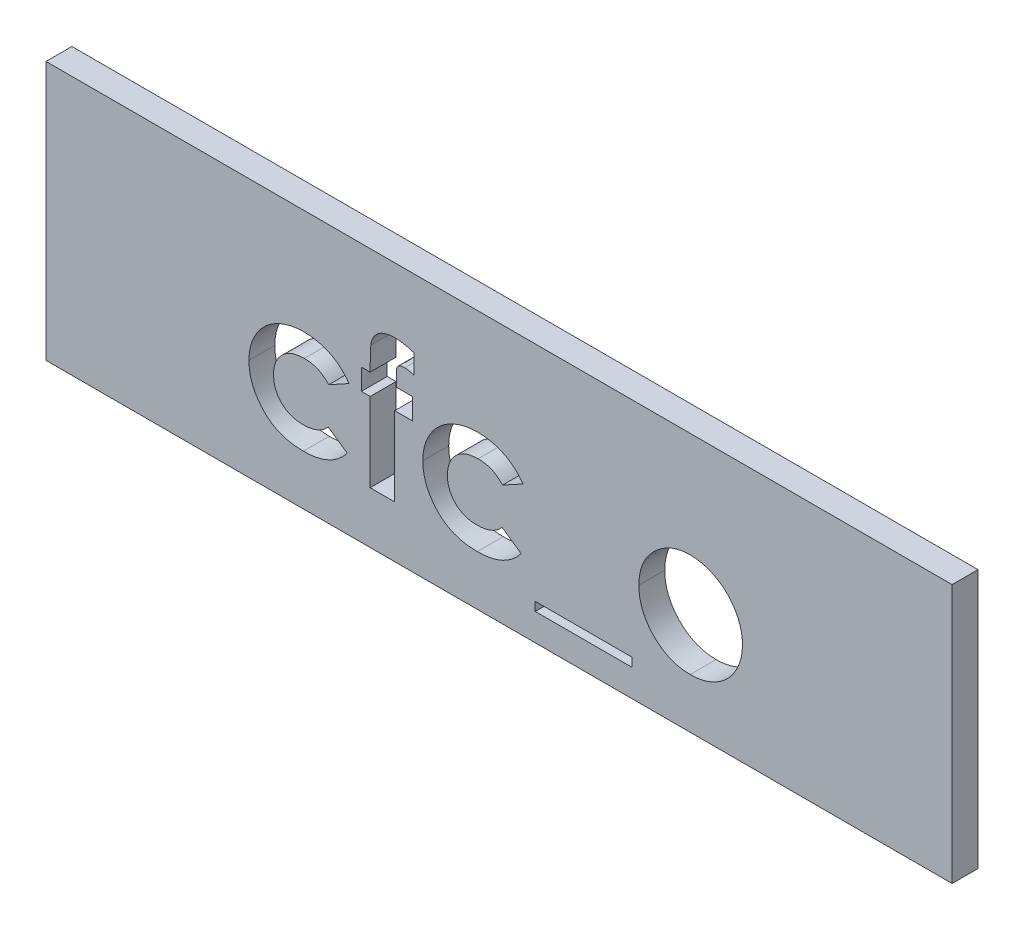
from build123d import *

# Parameters (mm, degrees)
ESQUISSE1_W             = 35
ESQUISSE1_H             = 10
BOSS_EXTRU_1_DEPTH      = 1
ESQUISSE2_R             = 1
BOSS_EXTRU_2_DEPTH      = 3
CHANFREIN1_SIZE         = 0.5
ESQUISSE3_W             = 3.731303419
ESQUISSE3_H             = 0.339209402
ENL_V_MAT_EXTRU_2_DEPTH = 1


with BuildPart() as part:
    # Esquisse1 → Boss.-Extru.1 (new body)
    with BuildSketch(Plane.XY):
        with Locations((17.5, -5)):
            Rectangle(ESQUISSE1_W, ESQUISSE1_H)
    extrude(amount=BOSS_EXTRU_1_DEPTH)

    # Esquisse2 → Boss.-Extru.2 (add)
    with BuildSketch(Plane(origin=(0, 0, 0), x_dir=(-1, 0, 0), z_dir=(0, 0, -1))):
        with Locations(Location((-30, -5, 0), (0, 0, 180))):  # turned: the seam where the file's is
            Circle(ESQUISSE2_R)
        with Locations(Location((-5, -5, 0), (0, 0, 180))):  # turned: the seam where the file's is
            Circle(ESQUISSE2_R)
    extrude(amount=BOSS_EXTRU_2_DEPTH)

    # Chanfrein1
    chanfrein1_edges = [part.edges().sort_by_distance(p)[0] for p in [
        (29, -5, -3),
        (4, -5, -3),
    ]]
    chamfer(chanfrein1_edges, length=CHANFREIN1_SIZE)

    # Esquisse3 → Enlèv. mat.-Extru.2 (cut)
    with BuildSketch(Plane.XY.offset(1)):
        with BuildLine():
            Line((11.706196581, -4.921674679), (10.919654781, -5.354166667))
            add(Edge.make_bspline(
                [(10.919654781, -5.354166667), (10.883602572, -5.318063555), (10.814301161, -5.248664299), (10.70317078, -5.16081585), (10.594026153, -5.088079778), (10.482367698, -5.034404293), (10.367197322, -4.993981508), (10.244360969, -4.96720861), (10.112424923, -4.949579608), (10.02116461, -4.947953728), (9.974108574, -4.947115385)],
                knots=[0, 0, 0, 0, 1.150764855, 2.212059359, 3.192108068, 4.105322427, 5.000809612, 5.941206042, 6.938435785, 8, 8, 8, 8], degree=3))
            add(Edge.make_bspline(
                [(9.974108574, -4.947115385), (9.930954941, -4.948157704), (9.846506901, -4.950197436), (9.723114912, -4.965432834), (9.605843472, -4.989361835), (9.494903088, -5.024370047), (9.390491357, -5.0706178), (9.291744837, -5.12534506), (9.199623087, -5.190689399), (9.115428271, -5.265721963), (9.039427651, -5.348331153), (8.971631221, -5.436437405), (8.916089934, -5.531347754), (8.868071046, -5.630831462), (8.832766975, -5.736757056), (8.806937657, -5.848163371), (8.792215187, -5.965055344), (8.790082161, -6.044912531), (8.788995726, -6.085586939)],
                knots=[0, 0, 0, 0, 1.121765476, 2.195200973, 3.227634963, 4.230038321, 5.213228299, 6.192116585, 7.160777141, 8.14345191, 9.118668839, 10.075979138, 11.027630062, 11.972829041, 12.943187208, 13.923755399, 14.94248691, 16, 16, 16, 16], degree=3))
            add(Edge.make_bspline(
                [(8.788995726, -6.085586939), (8.790143638, -6.125199879), (8.792385016, -6.202546952), (8.806155286, -6.316188233), (8.830060994, -6.424369883), (8.865904474, -6.526519978), (8.908866891, -6.623580196), (8.962819823, -6.714778598), (9.026265498, -6.800513425), (9.099537933, -6.880039516), (9.180705196, -6.951563477), (9.26820987, -7.01472654), (9.361790878, -7.068277132), (9.462538343, -7.110302311), (9.568809681, -7.144544041), (9.681314575, -7.168925493), (9.799933301, -7.182458885), (9.880792683, -7.184733534), (9.922167134, -7.185897436)],
                knots=[0, 0, 0, 0, 1.070556293, 2.090336998, 3.088792742, 4.058148387, 5.011235098, 5.952916408, 6.915475435, 7.888633318, 8.869583867, 9.83422472, 10.800707077, 11.776204622, 12.778807041, 13.814557445, 14.881744048, 16, 16, 16, 16], degree=3))
            add(Edge.make_bspline(
                [(9.922167134, -7.185897436), (9.973109, -7.184731737), (10.072540119, -7.182456462), (10.21708411, -7.163158313), (10.353098027, -7.131245961), (10.480596296, -7.08707673), (10.599400542, -7.029324638), (10.709205509, -6.958784767), (10.811139986, -6.875977477), (10.870582557, -6.811419049), (10.900574252, -6.778846154)],
                knots=[0, 0, 0, 0, 1.116373375, 2.178998604, 3.189797796, 4.174590301, 5.13072713, 6.078291395, 7.030403691, 8, 8, 8, 8], degree=3))
            Line((10.900574252, -6.778846154), (11.638354701, -7.285540198))
            add(Edge.make_bspline(
                [(11.638354701, -7.285540198), (11.587215304, -7.348064577), (11.486295592, -7.471451686), (11.310218681, -7.630493165), (11.120706742, -7.767145135), (10.913948281, -7.876219005), (10.692954383, -7.962973325), (10.455998195, -8.024300017), (10.203480511, -8.060400427), (10.030055809, -8.065321747), (9.941247663, -8.06784188)],
                knots=[0, 0, 0, 0, 0.997876357, 1.969233105, 2.924898516, 3.881013542, 4.852507933, 5.855329832, 6.901747111, 8, 8, 8, 8], degree=3))
            add(Edge.make_bspline(
                [(9.941247663, -8.06784188), (9.861314824, -8.06599407), (9.705197176, -8.062385093), (9.477659583, -8.034747141), (9.263648662, -7.988194771), (9.062724159, -7.923543097), (8.875069259, -7.839794971), (8.701292543, -7.735916003), (8.540221892, -7.614795726), (8.394763665, -7.475861975), (8.264981552, -7.324631087), (8.151681299, -7.165360916), (8.053694057, -7.000905122), (7.976823162, -6.828526399), (7.913998455, -6.650911564), (7.871568619, -6.465937483), (7.843583529, -6.275127813), (7.84067918, -6.145756539), (7.839209402, -6.080286792)],
                knots=[0, 0, 0, 0, 1.183377041, 2.311265848, 3.387807024, 4.421911742, 5.431260577, 6.423665966, 7.413571885, 8.409103097, 9.395976332, 10.359992013, 11.300391101, 12.225292883, 13.150239058, 14.085544813, 15.031169026, 16, 16, 16, 16], degree=3))
            add(Edge.make_bspline(
                [(7.839209402, -6.080286792), (7.839996772, -6.034673464), (7.841556312, -5.944327486), (7.854869845, -5.810153634), (7.875581229, -5.678256658), (7.906707994, -5.549562407), (7.94498842, -5.423446502), (7.991523461, -5.299934295), (8.048148632, -5.17966313), (8.111314181, -5.061609908), (8.183305316, -4.94889106), (8.261846151, -4.841556334), (8.346826029, -4.740263106), (8.439243248, -4.645955402), (8.538453418, -4.557958412), (8.643014279, -4.474486841), (8.75630937, -4.399845508), (8.874400116, -4.329668868), (8.998303747, -4.267198143), (9.12659616, -4.213277671), (9.258285941, -4.167464453), (9.393688745, -4.130629702), (9.532223395, -4.100271113), (9.675122604, -4.081004305), (9.821204122, -4.067462079), (9.920014916, -4.065939258), (9.969868456, -4.06517094)],
                knots=[0, 0, 0, 0, 1.00272354, 1.986087015, 2.96193297, 3.936200312, 4.894695956, 5.858592327, 6.835334787, 7.815655071, 8.800643866, 9.773423113, 10.738352213, 11.705312252, 12.673769326, 13.65298065, 14.64420052, 15.654211674, 16.672258995, 17.692438602, 18.712115155, 19.735602823, 20.776372304, 21.827874031, 22.90408564, 24, 24, 24, 24], degree=3))
            add(Edge.make_bspline(
                [(9.969868456, -4.06517094), (10.016175999, -4.065694486), (10.107504264, -4.06672703), (10.242375467, -4.07752371), (10.373567658, -4.095862345), (10.501304102, -4.120123587), (10.625972732, -4.150187491), (10.745902657, -4.190261668), (10.862733523, -4.235744349), (11.013212911, -4.304418449), (11.190600569, -4.406925659), (11.385324692, -4.553943595), (11.558944821, -4.725933137), (11.656851775, -4.856080703), (11.706196581, -4.921674679)],
                knots=[0, 0, 0, 0, 0.826738014, 1.630502179, 2.413926014, 3.191023582, 3.95155221, 4.701751672, 5.446919844, 6.189438973, 7.653650558, 9.094719814, 10.535747635, 12, 12, 12, 12], degree=3))
        make_face()
        with BuildLine():
            Line((12.181089744, -4.133012821), (12.520299145, -4.133012821))
            add(Edge.make_bspline(
                [(12.520299145, -4.133012821), (12.520525831, -4.071529895), (12.520954462, -3.955274043), (12.523485885, -3.790623415), (12.525192948, -3.645738514), (12.528242139, -3.520641627), (12.532533551, -3.415699183), (12.536932701, -3.330916919), (12.54022796, -3.265759909), (12.544873837, -3.229146271), (12.54679988, -3.213967348)],
                knots=[0, 0, 0, 0, 1.604323161, 3.033556972, 4.296844687, 5.385167547, 6.298701784, 7.037230881, 7.60086462, 8, 8, 8, 8], degree=3))
            add(Edge.make_bspline(
                [(12.54679988, -3.213967348), (12.555831324, -3.161890377), (12.573436665, -3.060374738), (12.631716029, -2.918882495), (12.716400643, -2.795626552), (12.806171533, -2.708625992), (12.889366133, -2.649232911), (12.959159489, -2.610441166), (13.035047047, -2.577184782), (13.117273996, -2.551107791), (13.205058304, -2.529806224), (13.299347317, -2.514998431), (13.399623732, -2.506838038), (13.468657605, -2.505495261), (13.50400641, -2.504807692)],
                knots=[0, 0, 0, 0, 1.43722947, 2.801646624, 4.13175475, 5.486897933, 6.18427957, 6.91287343, 7.658885333, 8.438447905, 9.260561323, 10.118602268, 11.036630026, 12, 12, 12, 12], degree=3))
            add(Edge.make_bspline(
                [(13.50400641, -2.504807692), (13.558166591, -2.506497842), (13.670971356, -2.510018085), (13.844286701, -2.538477083), (14.02816219, -2.582043201), (14.151954959, -2.622584077), (14.216346154, -2.643671541)],
                knots=[0, 0, 0, 0, 0.891275659, 1.856347963, 2.884972697, 4, 4, 4, 4], degree=3))
            Line((14.216346154, -2.643671541), (14.216346154, -3.382512019))
            add(Edge.make_bspline(
                [(14.216346154, -3.382512019), (14.181808981, -3.372963073), (14.115938875, -3.354751099), (14.021162226, -3.33453419), (13.935765591, -3.322050298), (13.8821175, -3.319911685), (13.856996194, -3.318910256)],
                knots=[0, 0, 0, 0, 1.174725213, 2.24046353, 3.176077791, 4, 4, 4, 4], degree=3))
            add(Edge.make_bspline(
                [(13.856996194, -3.318910256), (13.829348429, -3.319492882), (13.777540779, -3.320584631), (13.705727837, -3.334473818), (13.644240647, -3.35634296), (13.612348022, -3.381319103), (13.597288996, -3.393112313)],
                knots=[0, 0, 0, 0, 1.199997209, 2.248609783, 3.173030359, 4, 4, 4, 4], degree=3))
            add(Edge.make_bspline(
                [(13.597288996, -3.393112313), (13.588176407, -3.404752874), (13.568043721, -3.430470677), (13.549744402, -3.482949523), (13.540454041, -3.549278153), (13.538821694, -3.598364775), (13.53792735, -3.625258747)],
                knots=[0, 0, 0, 0, 0.721105823, 1.593158367, 2.681320256, 4, 4, 4, 4], degree=3))
            Line((13.53792735, -3.625258747), (13.534747262, -4.133012821))
            Line((13.534747262, -4.133012821), (14.148504274, -4.133012821))
            Line((14.148504274, -4.133012821), (14.148504274, -4.947115385))
            Line((14.148504274, -4.947115385), (13.47008547, -4.947115385))
            Line((13.47008547, -4.947115385), (13.47008547, -8))
            Line((13.47008547, -8), (12.520299145, -8))
            Line((12.520299145, -8), (12.520299145, -4.947115385))
            Line((12.520299145, -4.947115385), (12.181089744, -4.947115385))
            Line((12.181089744, -4.947115385), (12.181089744, -4.133012821))
        make_face()
        with BuildLine():
            Line((18.422542735, -4.921674679), (17.636000935, -5.354166667))
            add(Edge.make_bspline(
                [(17.636000935, -5.354166667), (17.599948725, -5.318063555), (17.530647315, -5.248664299), (17.419516934, -5.16081585), (17.310372306, -5.088079778), (17.198713852, -5.034404293), (17.083543476, -4.993981508), (16.960707123, -4.96720861), (16.828771077, -4.949579608), (16.737510764, -4.947953728), (16.690454728, -4.947115385)],
                knots=[0, 0, 0, 0, 1.150764855, 2.212059359, 3.192108068, 4.105322427, 5.000809612, 5.941206042, 6.938435785, 8, 8, 8, 8], degree=3))
            add(Edge.make_bspline(
                [(16.690454728, -4.947115385), (16.647301095, -4.948157704), (16.562853054, -4.950197436), (16.439461066, -4.965432834), (16.322189626, -4.989361835), (16.211249242, -5.024370047), (16.106837511, -5.0706178), (16.008090991, -5.12534506), (15.915969241, -5.190689399), (15.831774425, -5.265721963), (15.755773805, -5.348331153), (15.687977374, -5.436437405), (15.632436088, -5.531347754), (15.5844172, -5.630831462), (15.549113129, -5.736757056), (15.523283811, -5.848163371), (15.50856134, -5.965055344), (15.506428314, -6.044912531), (15.50534188, -6.085586939)],
                knots=[0, 0, 0, 0, 1.121765476, 2.195200973, 3.227634963, 4.230038321, 5.213228299, 6.192116585, 7.160777141, 8.14345191, 9.118668839, 10.075979138, 11.027630062, 11.972829041, 12.943187208, 13.923755399, 14.94248691, 16, 16, 16, 16], degree=3))
            add(Edge.make_bspline(
                [(15.50534188, -6.085586939), (15.506489792, -6.125199879), (15.508731169, -6.202546952), (15.52250144, -6.316188233), (15.546407148, -6.424369883), (15.582250627, -6.526519978), (15.625213045, -6.623580196), (15.679165977, -6.714778598), (15.742611652, -6.800513425), (15.815884086, -6.880039516), (15.89705135, -6.951563477), (15.984556024, -7.01472654), (16.078137032, -7.068277132), (16.178884497, -7.110302311), (16.285155835, -7.144544041), (16.397660729, -7.168925493), (16.516279455, -7.182458885), (16.597138837, -7.184733534), (16.638513288, -7.185897436)],
                knots=[0, 0, 0, 0, 1.070556293, 2.090336998, 3.088792742, 4.058148387, 5.011235098, 5.952916408, 6.915475435, 7.888633318, 8.869583867, 9.83422472, 10.800707077, 11.776204622, 12.778807041, 13.814557445, 14.881744048, 16, 16, 16, 16], degree=3))
            add(Edge.make_bspline(
                [(16.638513288, -7.185897436), (16.689455153, -7.184731737), (16.788886272, -7.182456462), (16.933430264, -7.163158313), (17.069444181, -7.131245961), (17.19694245, -7.08707673), (17.315746696, -7.029324638), (17.425551662, -6.958784767), (17.52748614, -6.875977477), (17.586928711, -6.811419049), (17.616920406, -6.778846154)],
                knots=[0, 0, 0, 0, 1.116373375, 2.178998604, 3.189797796, 4.174590301, 5.13072713, 6.078291395, 7.030403691, 8, 8, 8, 8], degree=3))
            Line((17.616920406, -6.778846154), (18.354700855, -7.285540198))
            add(Edge.make_bspline(
                [(18.354700855, -7.285540198), (18.303561458, -7.348064577), (18.202641746, -7.471451686), (18.026564835, -7.630493165), (17.837052896, -7.767145135), (17.630294434, -7.876219005), (17.409300537, -7.962973325), (17.172344349, -8.024300017), (16.919826665, -8.060400427), (16.746401962, -8.065321747), (16.657593817, -8.06784188)],
                knots=[0, 0, 0, 0, 0.997876357, 1.969233105, 2.924898516, 3.881013542, 4.852507933, 5.855329832, 6.901747111, 8, 8, 8, 8], degree=3))
            add(Edge.make_bspline(
                [(16.657593817, -8.06784188), (16.577660978, -8.06599407), (16.42154333, -8.062385093), (16.194005737, -8.034747141), (15.979994816, -7.988194771), (15.779070313, -7.923543097), (15.591415413, -7.839794971), (15.417638697, -7.735916003), (15.256568046, -7.614795726), (15.111109819, -7.475861975), (14.981327706, -7.324631087), (14.868027453, -7.165360916), (14.770040211, -7.000905122), (14.693169316, -6.828526399), (14.630344608, -6.650911564), (14.587914773, -6.465937483), (14.559929683, -6.275127813), (14.557025333, -6.145756539), (14.555555556, -6.080286792)],
                knots=[0, 0, 0, 0, 1.183377041, 2.311265848, 3.387807024, 4.421911742, 5.431260577, 6.423665966, 7.413571885, 8.409103097, 9.395976332, 10.359992013, 11.300391101, 12.225292883, 13.150239058, 14.085544813, 15.031169026, 16, 16, 16, 16], degree=3))
            add(Edge.make_bspline(
                [(14.555555556, -6.080286792), (14.556342926, -6.034673464), (14.557902466, -5.944327486), (14.571215999, -5.810153634), (14.591927383, -5.678256658), (14.623054147, -5.549562407), (14.661334574, -5.423446502), (14.707869615, -5.299934295), (14.764494786, -5.17966313), (14.827660335, -5.061609908), (14.89965147, -4.94889106), (14.978192305, -4.841556334), (15.063172183, -4.740263106), (15.155589402, -4.645955402), (15.254799572, -4.557958412), (15.359360433, -4.474486841), (15.472655523, -4.399845508), (15.590746269, -4.329668868), (15.714649901, -4.267198143), (15.842942314, -4.213277671), (15.974632095, -4.167464453), (16.110034899, -4.130629702), (16.248569549, -4.100271113), (16.391468758, -4.081004305), (16.537550276, -4.067462079), (16.63636107, -4.065939258), (16.68621461, -4.06517094)],
                knots=[0, 0, 0, 0, 1.00272354, 1.986087015, 2.96193297, 3.936200312, 4.894695956, 5.858592327, 6.835334787, 7.815655071, 8.800643866, 9.773423113, 10.738352213, 11.705312252, 12.673769326, 13.65298065, 14.64420052, 15.654211674, 16.672258995, 17.692438602, 18.712115155, 19.735602823, 20.776372304, 21.827874031, 22.90408564, 24, 24, 24, 24], degree=3))
            add(Edge.make_bspline(
                [(16.68621461, -4.06517094), (16.732522152, -4.065694486), (16.823850418, -4.06672703), (16.958721621, -4.07752371), (17.089913812, -4.095862345), (17.217650256, -4.120123587), (17.342318886, -4.150187491), (17.462248811, -4.190261668), (17.579079676, -4.235744349), (17.729559065, -4.304418449), (17.906946723, -4.406925659), (18.101670846, -4.553943595), (18.275290975, -4.725933137), (18.373197929, -4.856080703), (18.422542735, -4.921674679)],
                knots=[0, 0, 0, 0, 0.826738014, 1.630502179, 2.413926014, 3.191023582, 3.95155221, 4.701751672, 5.446919844, 6.189438973, 7.653650558, 9.094719814, 10.535747635, 12, 12, 12, 12], degree=3))
        make_face()
        with Locations((20.763087607, -8.780181624)):
            Rectangle(ESQUISSE3_W, ESQUISSE3_H)
        with BuildLine():
            add(Edge.make_bspline(
                [(24.878121661, -4.06517094), (24.923025725, -4.065970039), (25.011956119, -4.067552616), (25.14440683, -4.080726126), (25.274541998, -4.102219251), (25.403109621, -4.130049096), (25.52891583, -4.169042871), (25.652620462, -4.215809874), (25.775329594, -4.269503864), (25.893997611, -4.333418492), (26.009481799, -4.402739736), (26.118967682, -4.479206755), (26.221546055, -4.562218928), (26.319121123, -4.649851552), (26.407145729, -4.745919865), (26.491245118, -4.845794894), (26.566875605, -4.953054811), (26.636898542, -5.065085941), (26.699239459, -5.18124043), (26.75337108, -5.300710266), (26.800352237, -5.421843694), (26.837137542, -5.546116201), (26.867592384, -5.67188909), (26.886811554, -5.800703613), (26.900475051, -5.931236522), (26.902007163, -6.019122018), (26.902777778, -6.063326322)],
                knots=[0, 0, 0, 0, 1.022364134, 2.024744242, 3.027414945, 4.024939316, 5.017584196, 6.023349371, 7.035562955, 8.064994934, 9.090267829, 10.101425541, 11.102933353, 12.093946398, 13.084502048, 14.067315274, 15.065326281, 16.070028806, 17.074376865, 18.064572984, 19.055292013, 20.030201733, 21.013838017, 21.999348303, 22.993720005, 24, 24, 24, 24], degree=3))
            add(Edge.make_bspline(
                [(26.902777778, -6.063326322), (26.901964521, -6.107875973), (26.900347582, -6.196450777), (26.887305883, -6.328211509), (26.865730489, -6.457631787), (26.837793832, -6.585474047), (26.798945983, -6.710102427), (26.753556417, -6.833353996), (26.69783894, -6.953548791), (26.636239164, -7.071998023), (26.565766009, -7.185216092), (26.490200989, -7.293550495), (26.406453849, -7.394159111), (26.319133904, -7.490162093), (26.224099372, -7.57831305), (26.122867181, -7.660043319), (26.01631372, -7.736352088), (25.903672758, -7.805449009), (25.786387037, -7.866162011), (25.666434559, -7.920899736), (25.543113909, -7.9664728), (25.416680306, -8.003636379), (25.287057071, -8.032411209), (25.154530379, -8.051958292), (25.019385645, -8.065553064), (24.928330444, -8.06707403), (24.882361779, -8.06784188)],
                knots=[0, 0, 0, 0, 1.012026251, 2.012137606, 3.004615893, 3.992048833, 4.982446996, 5.968083444, 6.973977695, 7.990229942, 8.999482246, 10.001782172, 10.988562221, 11.971415814, 12.948383116, 13.930088534, 14.925840678, 15.924049238, 16.929462851, 17.924729459, 18.917889337, 19.913673841, 20.916777188, 21.931792057, 22.95587778, 24, 24, 24, 24], degree=3))
            add(Edge.make_bspline(
                [(24.882361779, -8.06784188), (24.815146217, -8.065868971), (24.682663321, -8.061980337), (24.487547337, -8.03534421), (24.300105285, -7.989496451), (24.120031732, -7.925585687), (23.947092756, -7.843686424), (23.78279763, -7.742323649), (23.625512067, -7.623492905), (23.477960371, -7.488198559), (23.342783028, -7.339768411), (23.224689355, -7.181320132), (23.124418271, -7.015228595), (23.042059987, -6.841304401), (22.978496187, -6.659309053), (22.932592278, -6.469786652), (22.905923585, -6.272204479), (22.90206784, -6.137961452), (22.900106838, -6.069686498)],
                knots=[0, 0, 0, 0, 1.029999031, 2.030143771, 3.011211297, 3.982305373, 4.953580601, 5.938004764, 6.935448627, 7.970290061, 9.001484052, 10.007591832, 10.993831261, 11.969999897, 12.951306496, 13.942897864, 14.953773953, 16, 16, 16, 16], degree=3))
            add(Edge.make_bspline(
                [(22.900106838, -6.069686498), (22.902136226, -5.996783815), (22.906124947, -5.85349505), (22.937797152, -5.643573745), (22.988374246, -5.442584044), (23.060974479, -5.251088178), (23.153714892, -5.068732961), (23.266929917, -4.895902998), (23.401179072, -4.732559142), (23.503987042, -4.633763179), (23.556265024, -4.583525307)],
                knots=[0, 0, 0, 0, 1.043912699, 2.05178951, 3.033892, 4.007821512, 4.978932272, 5.95884105, 6.962068106, 8, 8, 8, 8], degree=3))
            add(Edge.make_bspline(
                [(23.556265024, -4.583525307), (23.604235298, -4.541883762), (23.698870719, -4.459733615), (23.85262213, -4.35553962), (24.010046226, -4.265547797), (24.173029802, -4.19155778), (24.342027214, -4.135770502), (24.516172446, -4.095162354), (24.695429287, -4.07021964), (24.81691473, -4.066862392), (24.878121661, -4.06517094)],
                knots=[0, 0, 0, 0, 1.048115528, 2.067714963, 3.060638214, 4.039924844, 5.017819947, 5.994373833, 6.98952318, 8, 8, 8, 8], degree=3))
        make_face()
    extrude(amount=-ENL_V_MAT_EXTRU_2_DEPTH, mode=Mode.SUBTRACT)


solid = part.part
